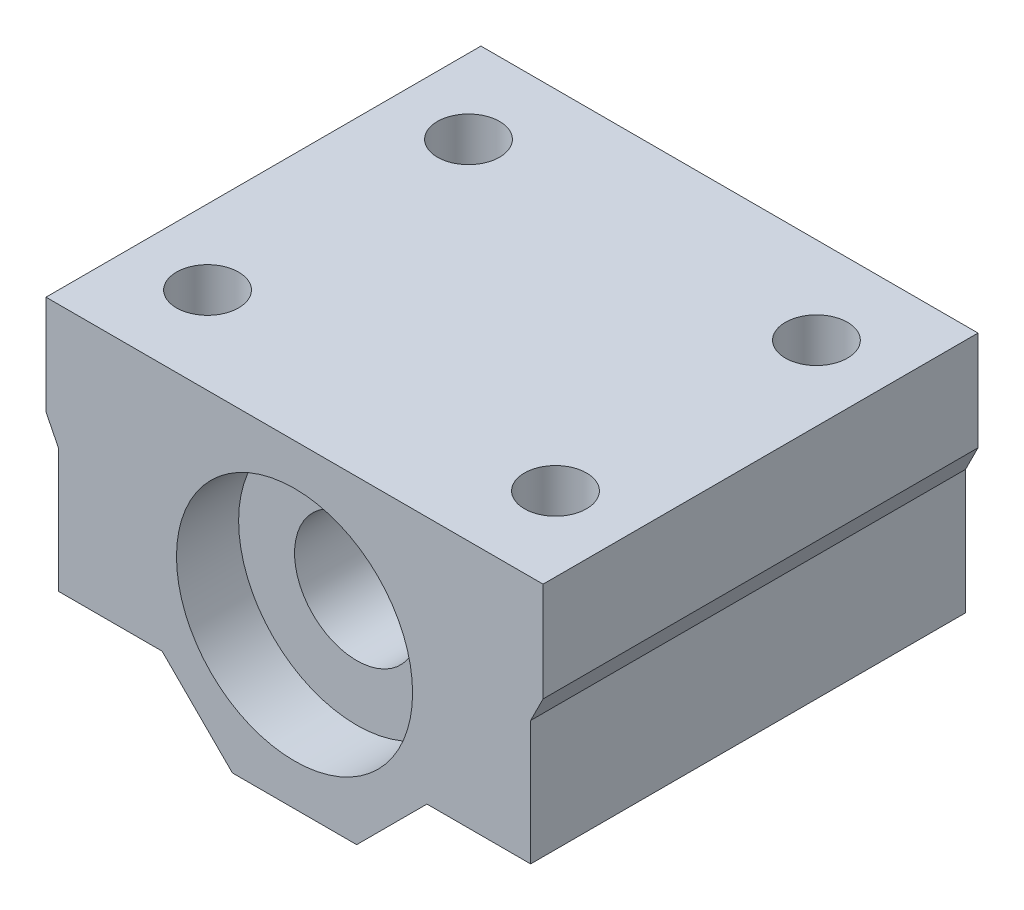
from build123d import *

# Parameters (mm, degrees)
BOSS_EXTRUDE1_DEPTH = 35
SKETCH3_R           = 9.5
CUT_EXTRUDE1_DEPTH  = 5
SKETCH4_R           = 5
CUT_EXTRUDE2_DEPTH  = 31
SKETCH5_R           = 2.5
CUT_EXTRUDE3_DEPTH  = 26.656854249


with BuildPart() as part:
    # Sketch2 → Boss-Extrude1 (new body)
    with BuildSketch(Plane.XY):
        Polygon((-5, 0), (5, 0), (10.656854249, 5.656854249), (19, 5.656854249), (19, 15.656854249), (20, 17.656854249), (20, 25.656854249), (-20, 25.656854249), (-20, 17.656854249), (-19, 15.656854249), (-19, 5.656854249), (-10.656854249, 5.656854249), align=None)
    extrude(amount=BOSS_EXTRUDE1_DEPTH)

    # Sketch3 → Cut-Extrude1 (cut)
    with BuildSketch(Plane.XY.offset(35)):
        with Locations((0, 12.828427125)):
            Circle(SKETCH3_R)
    cut_extrude1 = extrude(amount=-CUT_EXTRUDE1_DEPTH, mode=Mode.SUBTRACT)

    # Sketch4 → Cut-Extrude2 (cut, through all)
    with BuildSketch(Plane.XY.offset(30)):
        with Locations((0, 12.828427125)):
            Circle(SKETCH4_R)
    extrude(amount=-CUT_EXTRUDE2_DEPTH, mode=Mode.SUBTRACT)

    # Mirror1: Cut-Extrude1 across plane
    add(cut_extrude1.mirror(Plane.XY.offset(17.5)), mode=Mode.SUBTRACT)

    # Sketch5 → Cut-Extrude3 (cut, through all)
    with BuildSketch(Plane(origin=(0, 25.656854249, 0), x_dir=(1, 0, 0), z_dir=(0, 1, 0))):
        with Locations((-14, -7)):
            Circle(SKETCH5_R)
        with Locations((14, -7)):
            Circle(SKETCH5_R)
        with Locations((14, -28)):
            Circle(SKETCH5_R)
        with Locations((-14, -28)):
            Circle(SKETCH5_R)
    extrude(amount=-CUT_EXTRUDE3_DEPTH, mode=Mode.SUBTRACT)


solid = part.part
